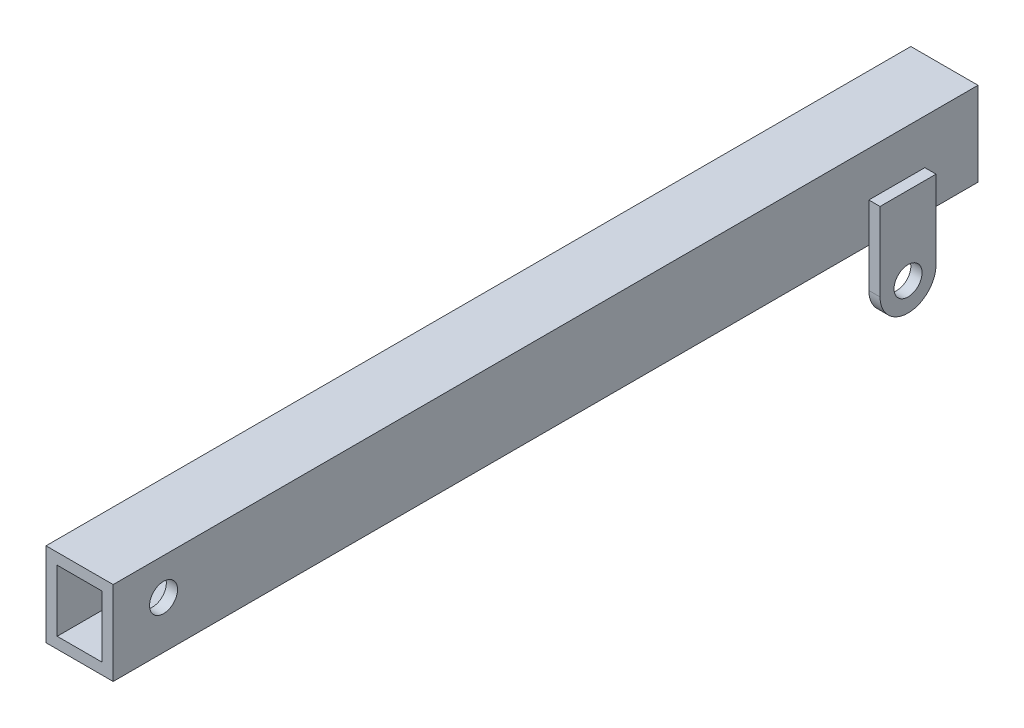
from build123d import *

# Parameters (mm, degrees)
CROQUIS1_W                = 12
CROQUIS1_H                = 15
CROQUIS1_W_2              = 8
CROQUIS1_H_2              = 11
SALIENTE_EXTRUIR1_DEPTH   = 159.5
CROQUIS2_R                = 2.5
SALIENTE_EXTRUIR2_DEPTH   = 2
SIMETR_A2_COPY_1_SKETCH_R = 2.5
SIMETR_A2_COPY_1_DEPTH    = 2
SKETCH1_W                 = 159.5
SKETCH1_H                 = 34.305734292
CUT_EXTRUDE1_DEPTH        = 3
CUT_EXTRUDE1_DEPTH_BACK   = 15
SKETCH5_R                 = 2.5
CUT_EXTRUDE2_DEPTH        = 15
SKETCH6_W                 = 5
SKETCH6_H                 = 15
CUT_EXTRUDE3_DEPTH        = 3
CUT_EXTRUDE3_DEPTH_BACK   = 15


with BuildPart() as part:
    # Croquis1 → Saliente-Extruir1 (new body, symmetric)
    with BuildSketch(Plane.XY):
        Rectangle(CROQUIS1_W, CROQUIS1_H)
        Rectangle(CROQUIS1_W_2, CROQUIS1_H_2, mode=Mode.SUBTRACT)
    extrude(amount=SALIENTE_EXTRUIR1_DEPTH, both=True)

    # Croquis2 → Saliente-Extruir2 (add)
    with BuildSketch(Plane(origin=(6, 0, 0), x_dir=(0, 0, -1), z_dir=(1, 0, 0))):
        with BuildLine():
            Line((-145, -14.5), (-145, -0.5))
            Line((-145, -0.5), (-135, -0.5))
            Line((-135, -0.5), (-135, -14.5))
            ThreePointArc((-135, -14.5), (-140, -19.5), (-145, -14.5))
        make_face()
        with Locations((-140, -14.5)):
            Circle(CROQUIS2_R, mode=Mode.SUBTRACT)
    saliente_extruir2 = extrude(amount=SALIENTE_EXTRUIR2_DEPTH)

    # Simetría1: Saliente-Extruir2 across plane
    add(saliente_extruir2.mirror(Plane(origin=(0, 0, 0), x_dir=(0, 0, 1), z_dir=(1, 0, 0))))

    # Simetría2: Saliente-Extruir2 across plane
    add(saliente_extruir2.mirror(Plane.XY))

    # Simetría2 copy 1 sketch → Simetría2 copy 1 (add)
    with BuildSketch(Plane.ZY.offset(6)):
        with BuildLine():
            Line((-145, -14.5), (-145, -0.5))
            Line((-145, -0.5), (-135, -0.5))
            Line((-135, -0.5), (-135, -14.5))
            ThreePointArc((-135, -14.5), (-140, -19.5), (-145, -14.5))
        make_face()
        with Locations((-140, -14.5)):
            Circle(SIMETR_A2_COPY_1_SKETCH_R, mode=Mode.SUBTRACT)
    extrude(amount=SIMETR_A2_COPY_1_DEPTH)

    # Sketch1 → Cut-Extrude1 (cut, two sides)
    with BuildSketch(Plane(origin=(6, 0, 0), x_dir=(0, 0, -1), z_dir=(1, 0, 0))) as cut_extrude1_sk:
        with Locations((-79.75, -9.652867146)):
            Rectangle(SKETCH1_W, SKETCH1_H)
    extrude(amount=CUT_EXTRUDE1_DEPTH, mode=Mode.SUBTRACT)
    extrude(cut_extrude1_sk.sketch, amount=-CUT_EXTRUDE1_DEPTH_BACK, mode=Mode.SUBTRACT)

    # Sketch5 → Cut-Extrude2 (cut, through all)
    with BuildSketch(Plane.ZY.offset(6)):
        with Locations((-9, 1)):
            Circle(SKETCH5_R)
    extrude(amount=-CUT_EXTRUDE2_DEPTH, mode=Mode.SUBTRACT)

    # Sketch6 → Cut-Extrude3 (cut, two sides)
    with BuildSketch(Plane.ZY.offset(6)) as cut_extrude3_sk:
        with Locations((-157, 0)):
            Rectangle(SKETCH6_W, SKETCH6_H)
    extrude(amount=CUT_EXTRUDE3_DEPTH, mode=Mode.SUBTRACT)
    extrude(cut_extrude3_sk.sketch, amount=-CUT_EXTRUDE3_DEPTH_BACK, mode=Mode.SUBTRACT)


solid = part.part
